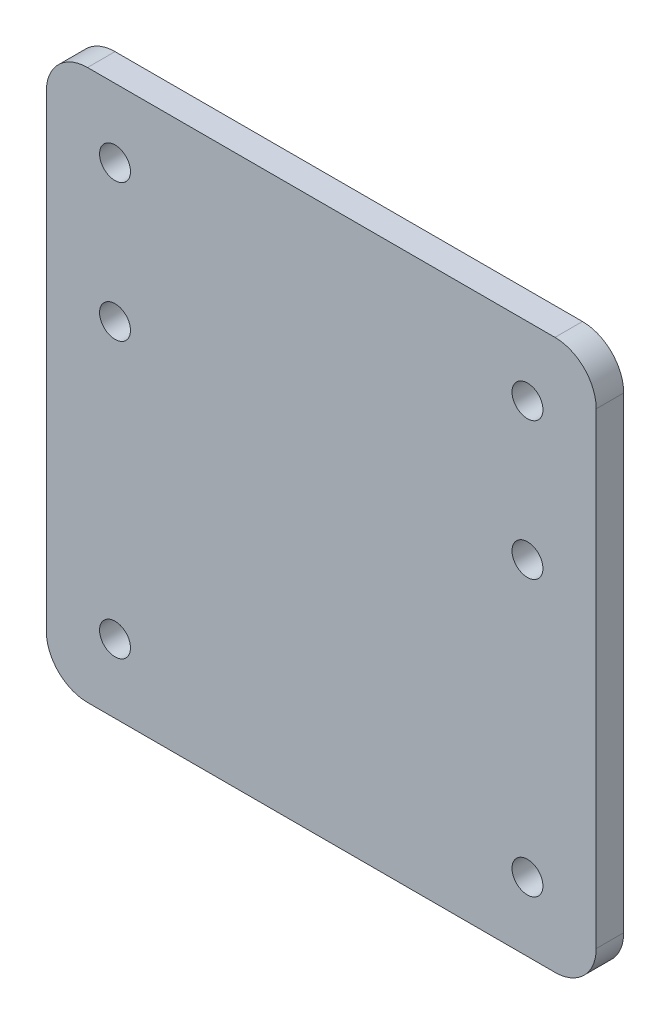
from build123d import *

# Parameters (mm, degrees)
SKETCH1_R           = 2.25
BOSS_EXTRUDE1_DEPTH = 4


with BuildPart() as part:
    # Sketch1 → Boss-Extrude1 (new body)
    with BuildSketch(Plane.XY):
        with BuildLine():
            Line((-34, -40), (34, -40))
            ThreePointArc((34, -40), (38.242640687, -38.242640687), (40, -34))
            Line((40, -34), (40, 34))
            ThreePointArc((40, 34), (38.242640687, 38.242640687), (34, 40))
            Line((34, 40), (-34, 40))
            ThreePointArc((-34, 40), (-38.242640687, 38.242640687), (-40, 34))
            Line((-40, 34), (-40, -34))
            ThreePointArc((-40, -34), (-38.242640687, -38.242640687), (-34, -40))
        make_face()
        with Locations((-30, 10)):
            Circle(SKETCH1_R, mode=Mode.SUBTRACT)
        with Locations((30, -30)):
            Circle(SKETCH1_R, mode=Mode.SUBTRACT)
        with Locations((30, 10)):
            Circle(SKETCH1_R, mode=Mode.SUBTRACT)
        with Locations((-30, 30)):
            Circle(SKETCH1_R, mode=Mode.SUBTRACT)
        with Locations((-30, -30)):
            Circle(SKETCH1_R, mode=Mode.SUBTRACT)
        with Locations((30, 30)):
            Circle(SKETCH1_R, mode=Mode.SUBTRACT)
    extrude(amount=BOSS_EXTRUDE1_DEPTH)


solid = part.part
